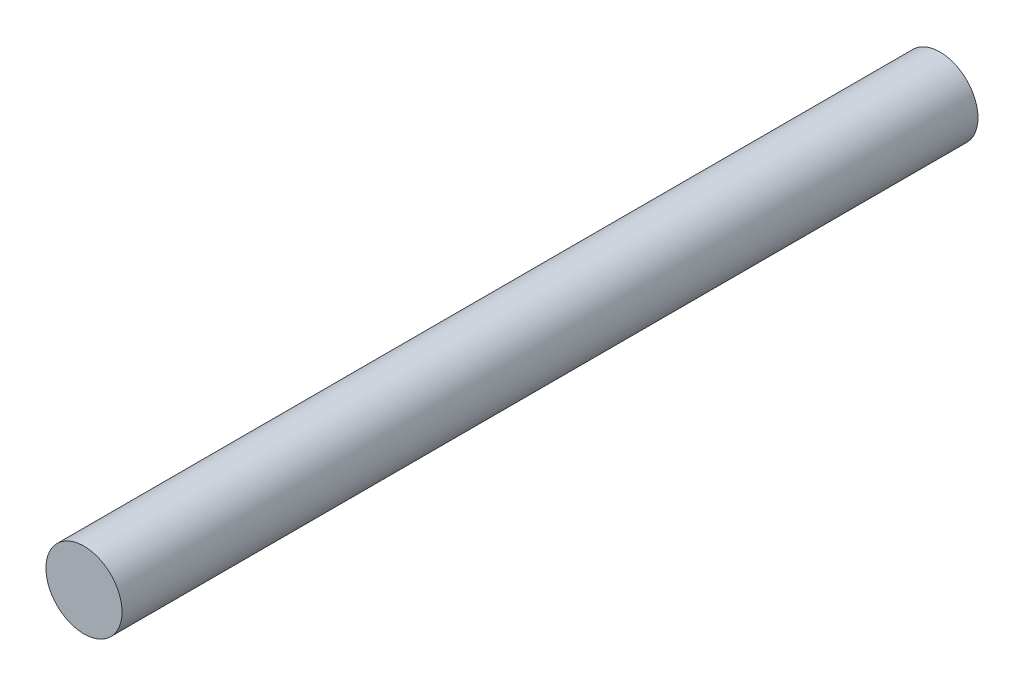
from build123d import *

# Parameters (mm, degrees)
SKETCH1_R           = 2
BOSS_EXTRUDE1_DEPTH = 45


with BuildPart() as part:
    # Sketch1 → Boss-Extrude1 (new body)
    with BuildSketch(Plane.XY):
        Circle(SKETCH1_R)
    extrude(amount=BOSS_EXTRUDE1_DEPTH)


solid = part.part
